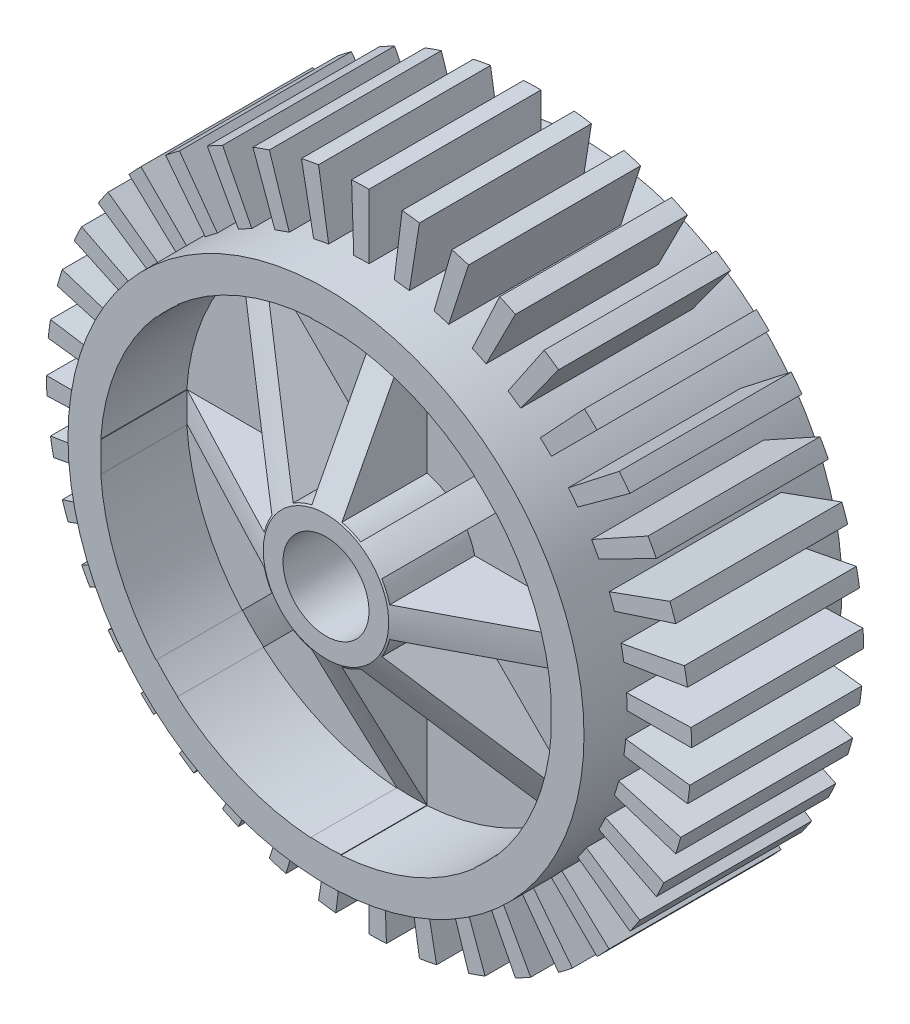
from build123d import *
from build123d.topology import SkipClean

# Parameters (mm, degrees)
SKETCH1_R               = 75
SKETCH1_R_2             = 10
BOSS_EXTRUDE1_DEPTH     = 30
SKETCH2_R               = 75
SKETCH2_R_2             = 60
CUT_EXTRUDE1_DEPTH      = 10
CUT_EXTRUDE4_DEPTH      = 111.227038425
CUT_EXTRUDE4_DEPTH_BACK = 20
CUT_EXTRUDE5_REACH      = 119.26
CIRPATTERN1_COUNT       = 40


with BuildPart() as part:
    # Sketch1 → Boss-Extrude1 (new body)
    with BuildSketch(Plane.XY):
        Circle(SKETCH1_R)
        Circle(SKETCH1_R_2, mode=Mode.SUBTRACT)
    extrude(amount=BOSS_EXTRUDE1_DEPTH)

    # Sketch2 → Cut-Extrude1 (cut)
    with BuildSketch(Plane(origin=(0, 0, 0), x_dir=(-1, 0, 0), z_dir=(0, 0, -1))):
        Circle(SKETCH2_R)
        Circle(SKETCH2_R_2, mode=Mode.SUBTRACT)
    extrude(amount=-CUT_EXTRUDE1_DEPTH, mode=Mode.SUBTRACT)

    # Sketch3 → Cut-Extrude4 (cut, two sides)
    with BuildSketch(Plane(origin=(0, 0, 0), x_dir=(-1, 0, 0), z_dir=(0, 0, -1))) as cut_extrude4_sk:
        with BuildLine():
            Line((-12.788699407, 7.838951938), (-39.515392089, 34.565644621))
            ThreePointArc((-39.515392089, 34.565644621), (-48.503675457, 20.090880199), (-52.383203415, 3.5))
            Line((-52.383203415, 3.5), (-14.585952146, 3.5))
            ThreePointArc((-14.585952146, 3.5), (-13.858192988, 5.740251485), (-12.788699407, 7.838951938))
        make_face()
        with BuildLine():
            Line((-3.5, 14.585952146), (-3.5, 52.383203415))
            ThreePointArc((-3.5, 52.383203415), (-20.090880199, 48.503675457), (-34.565644621, 39.515392089))
            Line((-34.565644621, 39.515392089), (-7.838951938, 12.788699407))
            ThreePointArc((-7.838951938, 12.788699407), (-5.740251485, 13.858192988), (-3.5, 14.585952146))
        make_face()
        with BuildLine():
            ThreePointArc((34.565644621, 39.515392089), (20.090880199, 48.503675457), (3.5, 52.383203415))
            Line((3.5, 52.383203415), (3.5, 14.585952146))
            ThreePointArc((3.5, 14.585952146), (5.740251485, 13.858192988), (7.838951938, 12.788699407))
            Line((7.838951938, 12.788699407), (34.565644621, 39.515392089))
        make_face()
        with BuildLine():
            ThreePointArc((52.383203415, 3.5), (48.503675457, 20.090880199), (39.515392089, 34.565644621))
            Line((39.515392089, 34.565644621), (12.788699407, 7.838951938))
            ThreePointArc((12.788699407, 7.838951938), (13.858192988, 5.740251485), (14.585952146, 3.5))
            Line((14.585952146, 3.5), (52.383203415, 3.5))
        make_face()
        with BuildLine():
            ThreePointArc((39.515392089, -34.565644621), (48.503675457, -20.090880199), (52.383203415, -3.5))
            Line((52.383203415, -3.5), (14.585952146, -3.5))
            ThreePointArc((14.585952146, -3.5), (13.858192988, -5.740251485), (12.788699407, -7.838951938))
            Line((12.788699407, -7.838951938), (39.515392089, -34.565644621))
        make_face()
        with BuildLine():
            ThreePointArc((7.838951938, -12.788699407), (5.740251485, -13.858192988), (3.5, -14.585952146))
            Line((3.5, -14.585952146), (3.5, -52.383203415))
            ThreePointArc((3.5, -52.383203415), (20.090880199, -48.503675457), (34.565644621, -39.515392089))
            Line((34.565644621, -39.515392089), (7.838951938, -12.788699407))
        make_face()
        with BuildLine():
            Line((-3.5, -52.383203415), (-3.5, -14.585952146))
            ThreePointArc((-3.5, -14.585952146), (-5.740251485, -13.858192988), (-7.838951938, -12.788699407))
            Line((-7.838951938, -12.788699407), (-34.565644621, -39.515392089))
            ThreePointArc((-34.565644621, -39.515392089), (-20.090880199, -48.503675457), (-3.5, -52.383203415))
        make_face()
        with BuildLine():
            Line((-14.585952146, -3.5), (-52.383203415, -3.5))
            ThreePointArc((-52.383203415, -3.5), (-48.503675457, -20.090880199), (-39.515392089, -34.565644621))
            Line((-39.515392089, -34.565644621), (-12.788699407, -7.838951938))
            ThreePointArc((-12.788699407, -7.838951938), (-13.858192988, -5.740251485), (-14.585952146, -3.5))
        make_face()
    extrude(amount=CUT_EXTRUDE4_DEPTH, mode=Mode.SUBTRACT)
    extrude(cut_extrude4_sk.sketch, amount=-CUT_EXTRUDE4_DEPTH_BACK, mode=Mode.SUBTRACT)

    # Sketch6 → Cut-Revolve2 (revolve, cut)
    with BuildSketch(Plane(origin=(0, 0, 0), x_dir=(0, 0, -1), z_dir=(1, 0, 0)), mode=Mode.PRIVATE) as cut_revolve2_sk:
        Polygon((0, -14.585952146), (-20, -52.383203415), (0, -52.383203415), align=None)
    revolve(cut_revolve2_sk.sketch.rotate(Axis((0, 0, 0), (0, 0, 1)), 270), axis=Axis((0, 0, 0), (0, 0, 1)), mode=Mode.SUBTRACT)

    # Mirror1: part across plane


with BuildPart() as part_1:
    add(part.part)
    add(part.part.mirror(Plane.XY.offset(30)))

    # Sketch7 → Cut-Extrude5 (cut, up to next)
    with BuildSketch(Plane.XY.offset(50), mode=Mode.PRIVATE) as cut_extrude5_sk1:
        with BuildLine():
            Line((0, 60), (0, 75))
            ThreePointArc((0, 75), (3.862551257, 74.900471946), (7.714850989, 74.602151941))
            Line((7.714850989, 74.602151941), (5.868144975, 59.712351106))
            ThreePointArc((5.868144975, 59.712351106), (2.937595417, 59.92804463), (0, 60))
        make_face()
    cut_extrude5_tool1 = extrude(cut_extrude5_sk1.sketch, amount=-CUT_EXTRUDE5_REACH, mode=Mode.PRIVATE) & part_1.part
    cut_extrude5 = cut_extrude5_tool1.solids().sort_by_distance((3.419597, 67.725028, 50))[0]
    add(cut_extrude5, mode=Mode.SUBTRACT)

    # CirPattern1: Cut-Extrude5 ×40 about axis
    with SkipClean():  # the faces are left unmerged after this step: merging them gives an invalid solid
        cirpattern1_axis = Axis((0, 0, 0), (0, 0, 1))
        for i in range(1, CIRPATTERN1_COUNT):
            add(cut_extrude5.rotate(cirpattern1_axis, i * 360 / CIRPATTERN1_COUNT), mode=Mode.SUBTRACT)


solid = part_1.part
